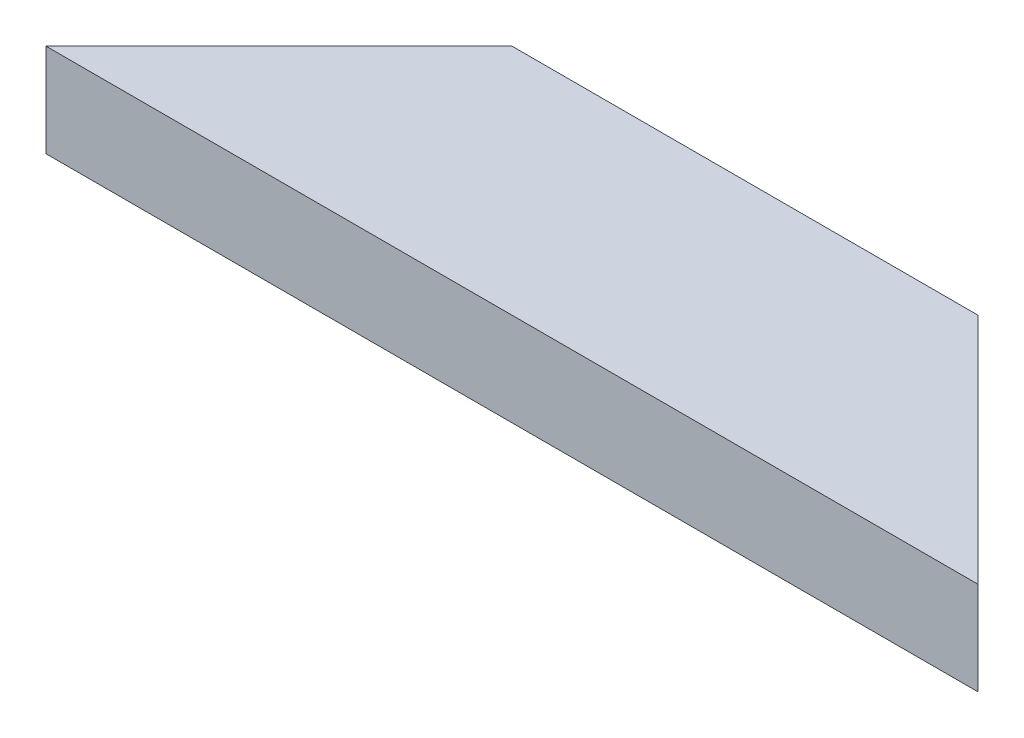
from build123d import *

# Parameters (mm, degrees)
BOSS_EXTRUDE1_DEPTH = 5


with BuildPart() as part:
    # Sketch1 → Boss-Extrude1 (new body, symmetric)
    with BuildSketch(Plane(origin=(0, 0, 0), x_dir=(1, 0, 0), z_dir=(0, 1, 0))):
        Polygon((25, 0), (-25, 0), (-50, -25), (50, -25), align=None)
    extrude(amount=BOSS_EXTRUDE1_DEPTH, both=True)


solid = part.part
